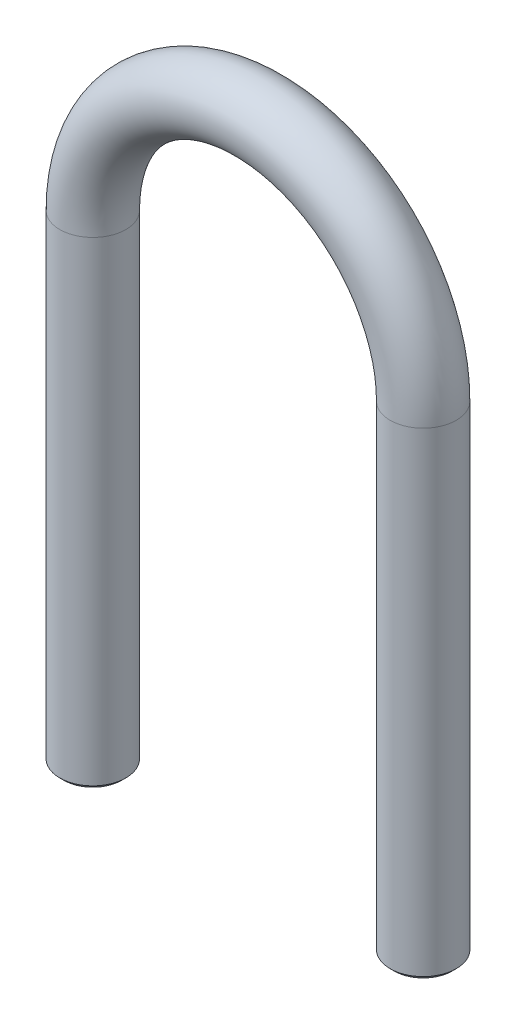
from build123d import *

# Parameters (mm, degrees)
SKETCH2_R     = 4
CHAMFER1_SIZE = 0.5


with BuildPart() as part:
    # Sweep1: sweep along a path in Sketch1
    with BuildLine(Plane.XY) as sweep1_path:
        Line((-20, -58), (-20, 0))
        ThreePointArc((-20, 0), (0, 20), (20, 0))
        Line((20, 0), (20, -58))
    # Sketch2 → Sweep1 (sweep)
    with BuildSketch(Plane(origin=(0, -58, 0), x_dir=(1, 0, 0), z_dir=(0, 1, 0))):
        with Locations((-20, 0)):
            Circle(SKETCH2_R)
    sweep(path=sweep1_path.line)

    # Chamfer1
    chamfer1_edges = [part.edges().sort_by_distance(p)[0] for p in [
        (-24, -58, 0),
        (24, -58, 0),
    ]]
    chamfer(chamfer1_edges, length=CHAMFER1_SIZE)


solid = part.part
